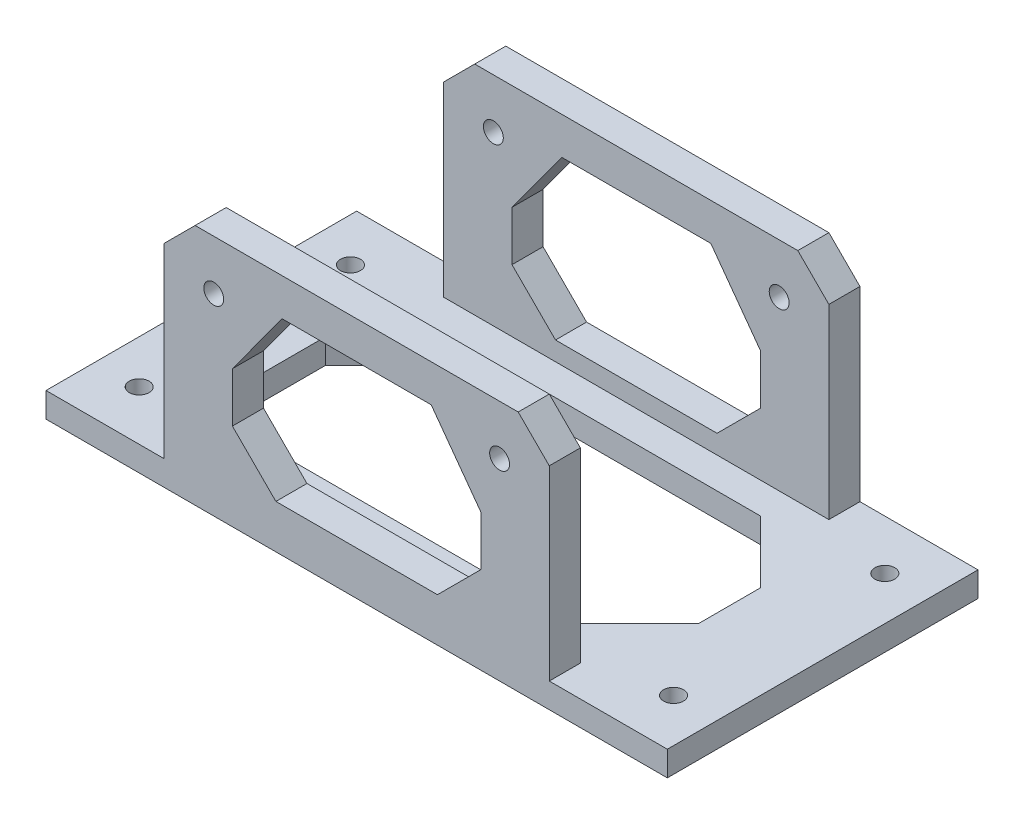
from build123d import *

# Parameters (mm, degrees)
SKETCH_1_W          = 100
SKETCH_1_H          = 50
SKETCH_1_R          = 1.6
EXTRUDE_1_DEPTH     = 4
SKETCH_2_W          = 72
SKETCH_2_H          = 5
EXTRUDE_2_DEPTH     = 35
SKETCH_3_R          = 1.6
CUT_EXTRUDE_1_DEPTH = 51
CUT_EXTRUDE_2_DEPTH = 51
CUT_EXTRUDE_3_DEPTH = 5


with BuildPart() as part:
    # 草图1 → 凸台-拉伸1 (new body)
    with BuildSketch(Plane(origin=(0, 0, 0), x_dir=(1, 0, 0), z_dir=(0, 1, 0))):
        Rectangle(SKETCH_1_W, SKETCH_1_H)
        with Locations((-43, 17)):
            Circle(SKETCH_1_R, mode=Mode.SUBTRACT)
        with Locations((-43, -17)):
            Circle(SKETCH_1_R, mode=Mode.SUBTRACT)
        with Locations((43, -17)):
            Circle(SKETCH_1_R, mode=Mode.SUBTRACT)
        with Locations((43, 17)):
            Circle(SKETCH_1_R, mode=Mode.SUBTRACT)
    extrude(amount=EXTRUDE_1_DEPTH)

    # 草图2 → 凸台-拉伸2 (add)
    with BuildSketch(Plane(origin=(0, 4, 0), x_dir=(1, 0, 0), z_dir=(0, 1, 0))):
        with Locations((0, 22.5)):
            Rectangle(SKETCH_2_W, SKETCH_2_H)
        with Locations((0, -22.5)):
            Rectangle(SKETCH_2_W, SKETCH_2_H)
    extrude(amount=EXTRUDE_2_DEPTH)

    # 草图3 → 切除-拉伸1 (cut, through all)
    with BuildSketch(Plane(origin=(0, 0, -25), x_dir=(-1, 0, 0), z_dir=(0, 0, -1))):
        with Locations((-23, 31)):
            Circle(SKETCH_3_R)
        with Locations((23, 31)):
            Circle(SKETCH_3_R)
        Polygon((-26, 39), (-36, 29), (-36, 39), align=None)
        Polygon((36, 39), (26, 39), (36, 29), align=None)
    extrude(amount=-CUT_EXTRUDE_1_DEPTH, mode=Mode.SUBTRACT)

    # 草图4 → 切除-拉伸2 (cut, through all)
    with BuildSketch(Plane(origin=(0, 0, -25), x_dir=(-1, 0, 0), z_dir=(0, 0, -1))):
        Polygon((12, 33), (-12, 33), (-20, 22.035391732), (-20, 14.035391732), (-13, 7.035391732), (13, 7.035391732), (20, 14.035391732), (20, 22.035391732), align=None)
        Polygon((-36, 4), (-31, 4), (-31, 34), (-36, 29), align=None)
        Polygon((31, 34), (36, 29), (36, 4), (31, 4), align=None)
    extrude(amount=-CUT_EXTRUDE_2_DEPTH, mode=Mode.SUBTRACT)

    # 草图5 → 切除-拉伸3 (cut, through all)
    with BuildSketch(Plane(origin=(0, 4, 0), x_dir=(1, 0, 0), z_dir=(0, 1, 0))):
        Polygon((-25, 15), (-35, 5), (-35, -5), (-25, -15), (25, -15), (35, -5), (35, 5), (25, 15), align=None)
    extrude(amount=-CUT_EXTRUDE_3_DEPTH, mode=Mode.SUBTRACT)


solid = part.part
